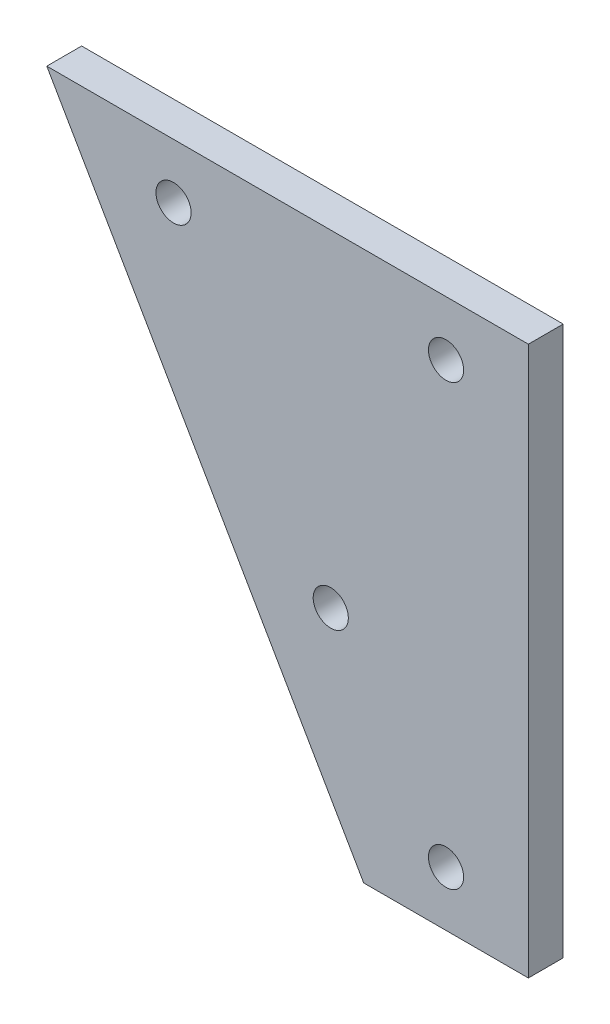
from build123d import *

# Parameters (mm, degrees)
SKETCH1_R           = 1.6
BOSS_EXTRUDE1_DEPTH = 3.175


with BuildPart() as part:
    # Sketch1 → Boss-Extrude1 (new body)
    with BuildSketch(Plane.XY):
        Polygon((0, 0), (43.867513459, 0), (43.867513459, -50), (28.867513459, -50), align=None)
        with Locations((36.367513459, -5)):
            Circle(SKETCH1_R, mode=Mode.SUBTRACT)
        with Locations((36.367513459, -45)):
            Circle(SKETCH1_R, mode=Mode.SUBTRACT)
        with Locations((11.547005384, -5)):
            Circle(SKETCH1_R, mode=Mode.SUBTRACT)
        with Locations((25.867513459, -29.803847577)):
            Circle(SKETCH1_R, mode=Mode.SUBTRACT)
    extrude(amount=BOSS_EXTRUDE1_DEPTH)


solid = part.part
